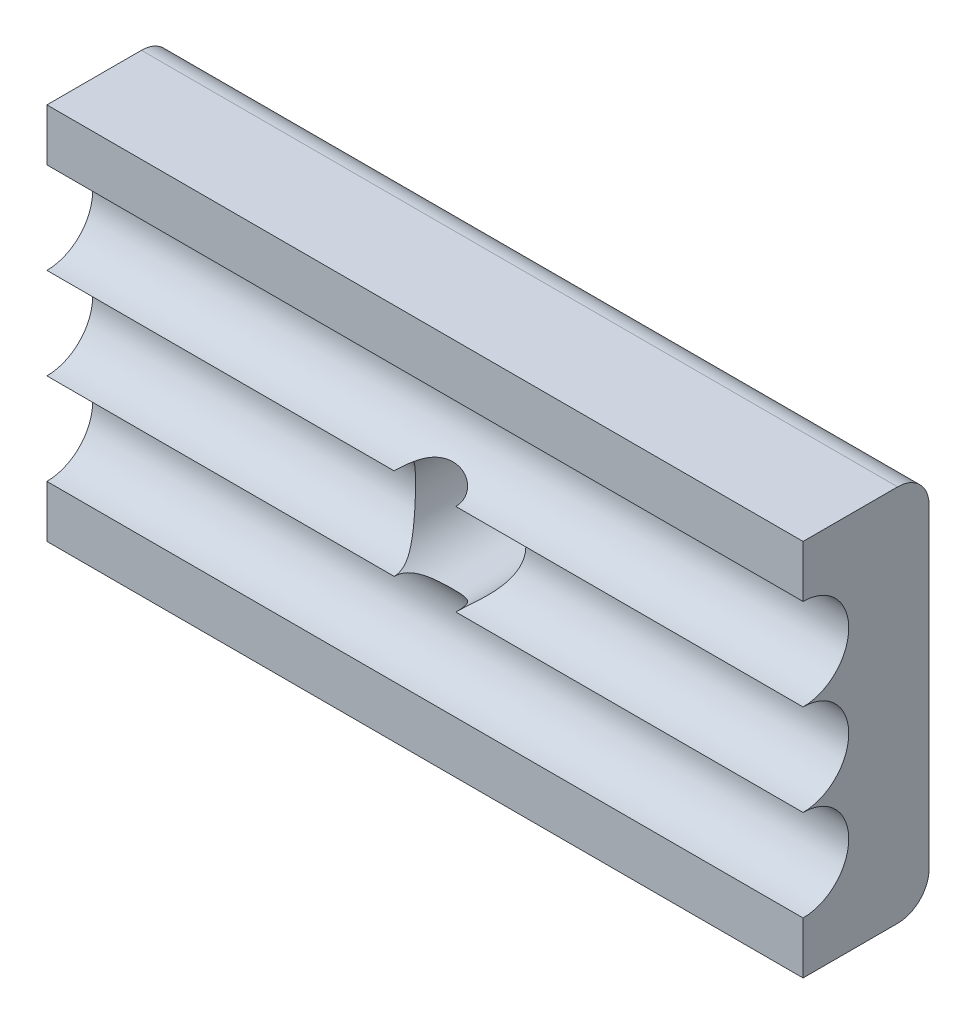
from build123d import *

# Parameters (mm, degrees)
SKETCH2_W           = 24
SKETCH2_H           = 12
BOSS_EXTRUDE1_DEPTH = 4
SKETCH3_R           = 1.75
CUT_EXTRUDE1_DEPTH  = 5
FILLET1_R           = 1
CUT_EXTRUDE2_DEPTH  = 32


with BuildPart() as part:
    # Sketch2 → Boss-Extrude1 (new body)
    with BuildSketch(Plane.XY):
        with Locations((6.957345972, -2)):
            Rectangle(SKETCH2_W, SKETCH2_H)
    extrude(amount=BOSS_EXTRUDE1_DEPTH)

    # Sketch3 → Cut-Extrude1 (cut)
    with BuildSketch(Plane.XY.offset(4)):
        with Locations((6.957345972, -2)):
            Circle(SKETCH3_R)
    extrude(amount=-CUT_EXTRUDE1_DEPTH, mode=Mode.SUBTRACT)

    # Fillet1
    fillet1_edges = [part.edges().sort_by_distance(p)[0] for p in [
        (6.957345972, 4, 0),
        (6.957345972, -8, 0),
    ]]
    fillet(fillet1_edges, radius=FILLET1_R)

    # Sketch4 → Cut-Extrude2 (cut)
    with BuildSketch(Plane.ZY.offset(5.042654028)):
        with BuildLine():
            ThreePointArc((5.45, -4.9), (5.025304833, -3.874695167), (4, -3.45))
            Line((4, -3.45), (4, -6.35))
            ThreePointArc((4, -6.35), (5.025304833, -5.925304833), (5.45, -4.9))
        make_face()
        with BuildLine():
            Line((4, -6.35), (4, -3.45))
            ThreePointArc((4, -3.45), (2.55, -4.9), (4, -6.35))
        make_face()
        with BuildLine():
            ThreePointArc((4, -3.45), (5.025304833, -3.025304833), (5.45, -2))
            ThreePointArc((5.45, -2), (5.025304833, -0.974695167), (4, -0.55))
            Line((4, -0.55), (4, -3.45))
        make_face()
        with BuildLine():
            Line((4, -3.45), (4, -0.55))
            ThreePointArc((4, -0.55), (2.55, -2), (4, -3.45))
        make_face()
        with BuildLine():
            ThreePointArc((4, 2.35), (2.55, 0.9), (4, -0.55))
            Line((4, -0.55), (4, 2.35))
        make_face()
        with BuildLine():
            Line((4, 2.35), (4, -0.55))
            ThreePointArc((4, -0.55), (5.025304833, -0.125304833), (5.45, 0.9))
            ThreePointArc((5.45, 0.9), (5.025304833, 1.925304833), (4, 2.35))
        make_face()
    extrude(amount=-CUT_EXTRUDE2_DEPTH, mode=Mode.SUBTRACT)


solid = part.part
